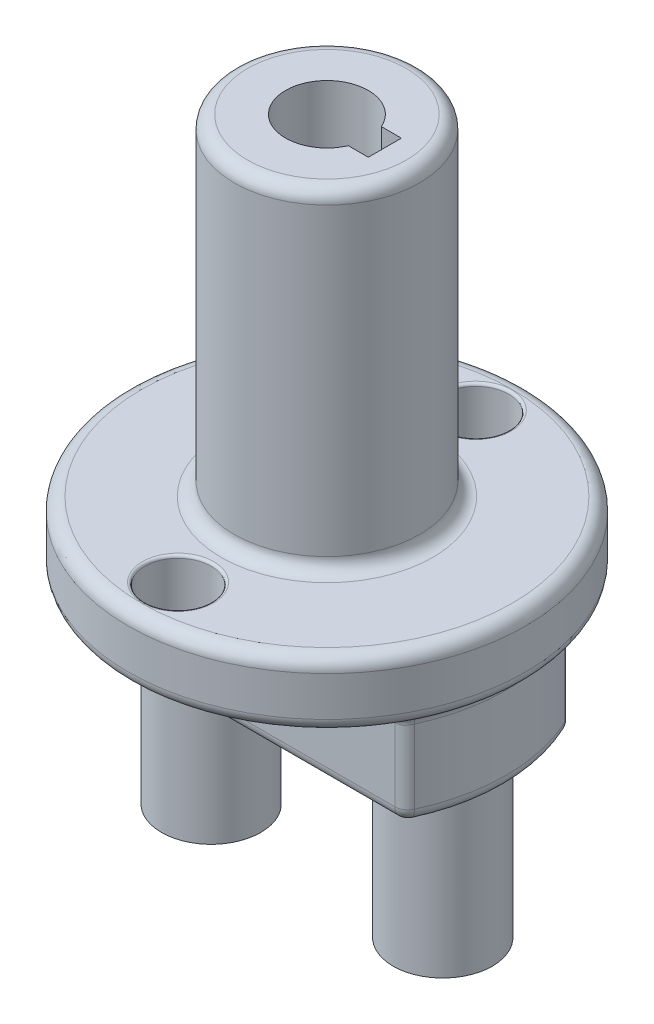
from build123d import *

# Parameters (mm, degrees)
SKETCH1_R          = 19.05
EXTRUDE1_DEPTH     = 6.35
EXTRUDE2_DEPTH     = 9.525
SKETCH3_R          = 8.89
EXTRUDE3_DEPTH     = 31.75
SKETCH4_R          = 3.96875
CUT_EXTRUDE1_DEPTH = 25.4
SKETCH5_R          = 4.7625
EXTRUDE4_DEPTH     = 15.24
SKETCH6_W          = 3.175
SKETCH6_H          = 3.175
CUT_EXTRUDE2_DEPTH = 25.4
FILLET1_R          = 1.27
FILLET2_R          = 1.27
SKETCH7_R          = 3.175
CUT_EXTRUDE3_DEPTH = 32.115
FILLET3_R          = 0.254


with BuildPart() as part:
    # Sketch1 → Extrude1 (new body)
    with BuildSketch(Plane(origin=(0, 0, 0), x_dir=(1, 0, 0), z_dir=(0, 1, 0))):
        with Locations(Location((0, 0, 0), (0, 0, 270))):  # turned: the seam where the file's is
            Circle(SKETCH1_R)
    extrude(amount=EXTRUDE1_DEPTH)

    # Sketch2 → Extrude2 (add)
    with BuildSketch(Plane.XZ):
        with BuildLine():
            Line((-15.24, 7.9375), (15.24, 7.9375))
            ThreePointArc((15.24, 7.9375), (17.183175092, 0), (15.24, -7.9375))
            Line((15.24, -7.9375), (-15.24, -7.9375))
            ThreePointArc((-15.24, -7.9375), (-17.183175092, 0), (-15.24, 7.9375))
        make_face()
    extrude(amount=EXTRUDE2_DEPTH)

    # Sketch3 → Extrude3 (add)
    with BuildSketch(Plane(origin=(0, 6.35, 0), x_dir=(-1, 0, 0), z_dir=(0, 1, 0))):
        with Locations(Location((0, 0, 0), (0, 0, 90))):  # turned: the seam where the file's is
            Circle(SKETCH3_R)
    extrude(amount=EXTRUDE3_DEPTH)

    # Sketch4 → Cut-Extrude1 (cut)
    with BuildSketch(Plane(origin=(0, 38.1, 0), x_dir=(-1, 0, 0), z_dir=(0, 1, 0))):
        with Locations(Location((0, 0, 0), (0, 0, 90))):  # turned: the seam where the file's is
            Circle(SKETCH4_R)
    extrude(amount=-CUT_EXTRUDE1_DEPTH, mode=Mode.SUBTRACT)

    # Sketch5 → Extrude4 (add)
    with BuildSketch(Plane.XZ.offset(9.525)):
        with Locations(Location((11.1125, 0, 0), (0, 0, 90))):  # turned: the seam where the file's is
            Circle(SKETCH5_R)
        with Locations(Location((-11.1125, 0, 0), (0, 0, 90))):  # turned: the seam where the file's is
            Circle(SKETCH5_R)
    extrude(amount=EXTRUDE4_DEPTH)

    # Sketch6 → Cut-Extrude2 (cut)
    with BuildSketch(Plane(origin=(0, 38.1, 0), x_dir=(-1, 0, 0), z_dir=(0, 1, 0))):
        with Locations((-3.96875, 0)):
            Rectangle(SKETCH6_W, SKETCH6_H)
    extrude(amount=-CUT_EXTRUDE2_DEPTH, mode=Mode.SUBTRACT)

    # Fillet1
    fillet1_edges = [part.edges().sort_by_distance(p)[0] for p in [
        (0, 0, -19.05),
        (0, 6.35, -8.89),
        (0, 38.1, -8.89),
        (0, 6.35, -19.05),
        (-15.24, -4.7625, 7.9375),
        (-15.24, -4.7625, -7.9375),
        (15.24, -4.7625, -7.9375),
        (15.24, -4.7625, 7.9375),
        (-17.183175092, -9.525, 0),
        (0, -9.525, -7.9375),
        (17.183175092, -9.525, 0),
        (0, -9.525, 7.9375),
    ]]
    fillet(fillet1_edges, radius=FILLET1_R)

    # Fillet2
    fillet2_edges = [part.edges().sort_by_distance(p)[0] for p in [
        (17.183175092, 0, 0),
        (0, 0, 7.9375),
        (-17.183175092, 0, 0),
        (0, 0, -7.9375),
        (-15.13350917, 0, -7.737241301),
        (15.13350917, 0, -7.737241301),
        (15.13350917, 0, 7.737241301),
        (-15.13350917, 0, 7.737241301),
    ]]
    fillet(fillet2_edges, radius=FILLET2_R)

    # Sketch7 → Cut-Extrude3 (cut, through all)
    with BuildSketch(Plane(origin=(0, 6.35, 0), x_dir=(-1, 0, 0), z_dir=(0, 1, 0))):
        with Locations(Location((0, 14.2875, 0), (0, 0, 90))):  # turned: the seam where the file's is
            Circle(SKETCH7_R)
        with Locations(Location((0, -14.2875, 0), (0, 0, 90))):  # turned: the seam where the file's is
            Circle(SKETCH7_R)
    extrude(amount=-CUT_EXTRUDE3_DEPTH, mode=Mode.SUBTRACT)

    # Fillet3
    fillet3_edges = [part.edges().sort_by_distance(p)[0] for p in [
        (0, 0, 11.1125),
        (0, 6.35, 11.1125),
        (0, 0, -17.4625),
        (0, 6.35, -17.4625),
    ]]
    fillet(fillet3_edges, radius=FILLET3_R)


solid = part.part
